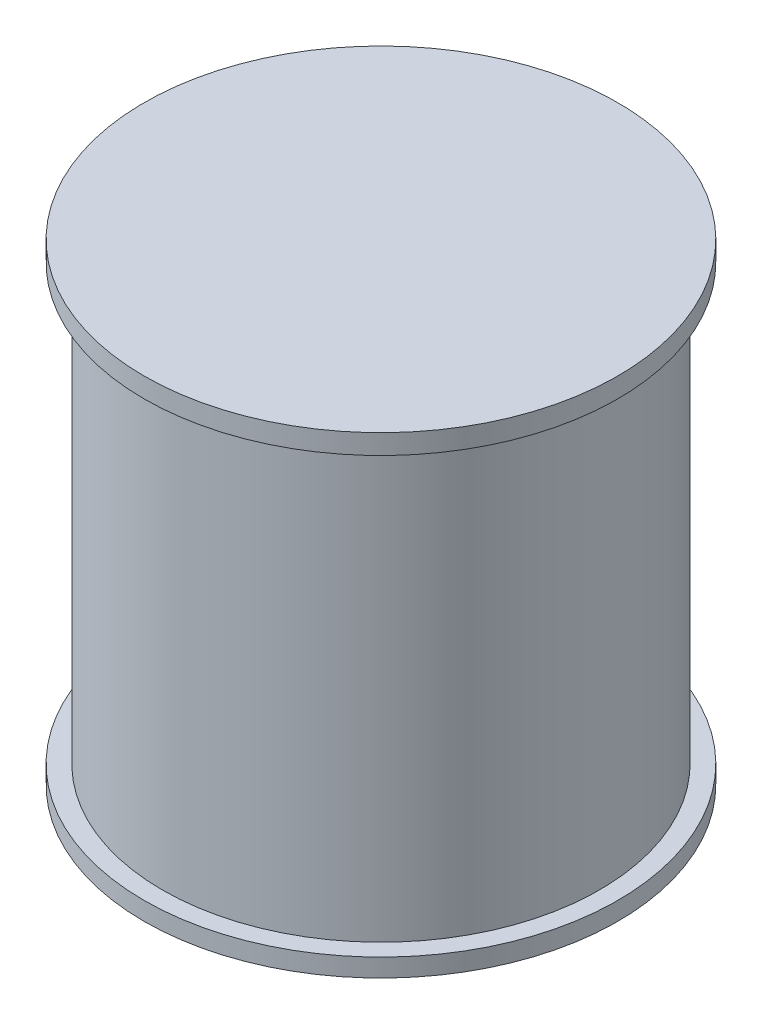
from build123d import *

# Parameters (mm, degrees)
CROQUIS3_W              = 2.5
CROQUIS3_H              = 93.200468797
CROQUIS3_H_2            = 93.221326365
SALIENTE_EXTRUIR1_DEPTH = 25
SALIENTE_EXTRUIR1_TAPER = 1


with BuildPart() as part:
    # Croquis1 → Revolución1 (revolve)
    with BuildSketch(Plane.XY):
        Polygon((0, 38.800633525), (0, -62.573128225), (50.821461866, -62.573128225), (50.821461866, -58.674137389), (46.92247103, -58.674137389), (46.92247103, 34.547188976), (50.821461866, 34.547188976), (50.821461866, 38.800633525), align=None)
    revolve(axis=Axis((0, 38.800633525, 0), (0, -1, 0)))

    # Croquis3 → Saliente-Extruir1 (add)
    with BuildSketch(Plane.XY):
        with Locations((-45.646866178, -12.07390299)):
            Rectangle(CROQUIS3_W, CROQUIS3_H)
        with Locations((-40.124494984, -12.063474207)):
            Rectangle(CROQUIS3_W, CROQUIS3_H_2)
    extrude(amount=-SALIENTE_EXTRUIR1_DEPTH, taper=SALIENTE_EXTRUIR1_TAPER)


solid = part.part
